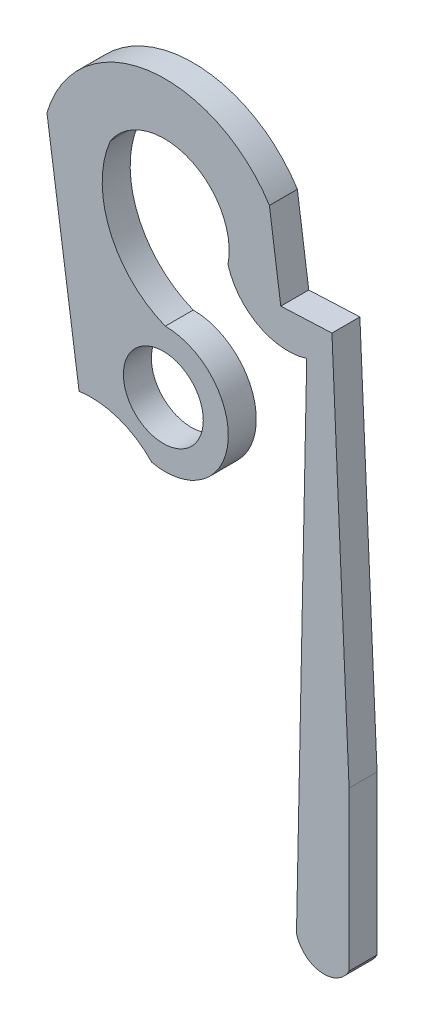
from build123d import *

# Parameters (mm, degrees)
SKETCH1_R           = 1.27
BOSS_EXTRUDE1_DEPTH = 0.889


with BuildPart() as part:
    # Sketch1 → Boss-Extrude1 (new body)
    with BuildSketch(Plane.XY):
        with BuildLine():
            Line((-4.521957117, 7.997023921), (-3.500640843, 0.843746079))
            ThreePointArc((-3.500640843, 0.843746079), (-2.247752793, 0.722417864), (-1.189432305, 0.040943912))
            ThreePointArc((-1.189432305, 0.040943912), (1.231506645, 1.78476828), (-0.761885285, 4.004736172))
            ThreePointArc((-0.761885285, 4.004736172), (-2.523808067, 5.75027928), (-2.507561872, 8.230406029))
            ThreePointArc((-2.507561872, 8.230406029), (-0.008086329, 8.999486055), (1.23243455, 6.697319679))
            ThreePointArc((1.23243455, 6.697319679), (2.203084663, 5.504138097), (3.734868812, 5.364562852))
            Line((3.734868812, 5.364562852), (3.409647754, -10.616831622))
            ThreePointArc((3.409647754, -10.616831622), (4.172569321, -11.302719528), (5.081281403, -10.826553706))
            Line((5.081281403, -10.826553706), (5.081281403, -5.788347659))
            Line((5.081281403, -5.788347659), (4.536062194, 6.463867416))
            Line((4.536062194, 6.463867416), (2.910345816, 6.391523616))
            Line((2.910345816, 6.391523616), (2.548786355, 8.982410145))
            ThreePointArc((2.548786355, 8.982410145), (-1.304965957, 10.774290658), (-4.521957117, 7.997023921))
        make_face()
        with Locations((-0.822961988, 2.012924292)):
            Circle(SKETCH1_R, mode=Mode.SUBTRACT)
    extrude(amount=BOSS_EXTRUDE1_DEPTH)


solid = part.part
